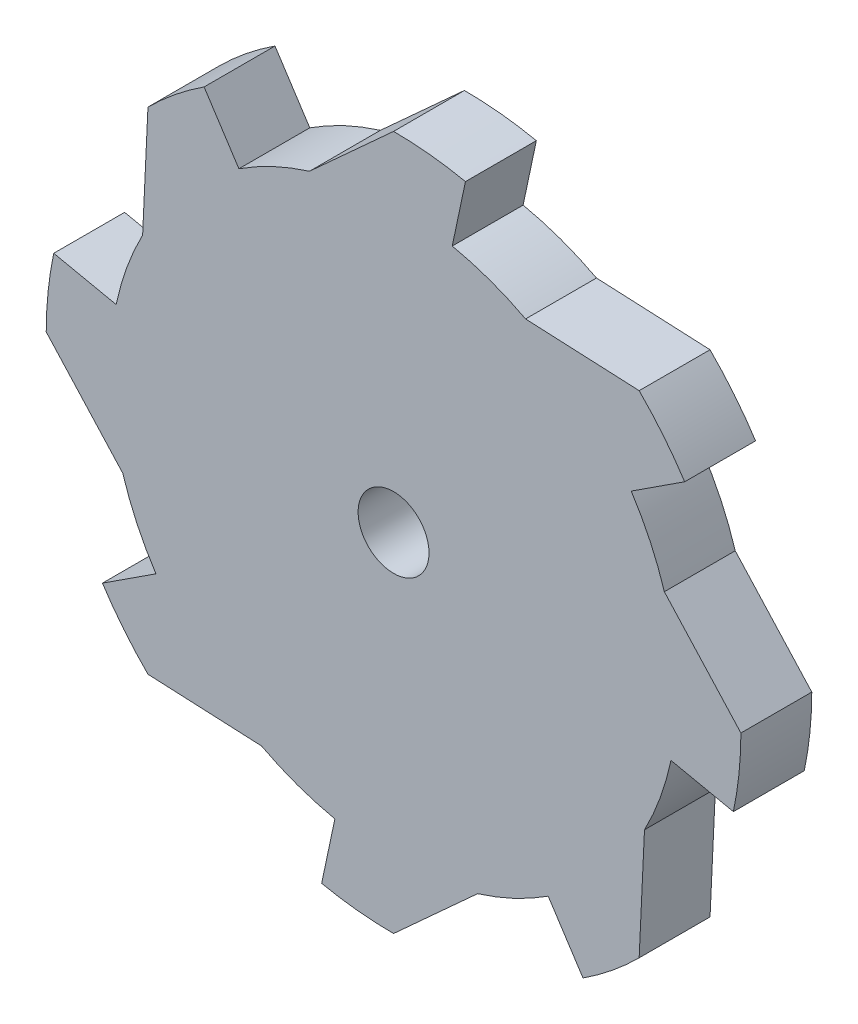
from build123d import *

# Parameters (mm, degrees)
BOSS_EXTRUDE1_DEPTH     = 20
CIRPATTERN1_COUNT       = 8
SKETCH3_R               = 10
CUT_EXTRUDE1_DEPTH      = 20
CUT_EXTRUDE1_DEPTH_BACK = 7


with BuildPart() as part:
    # Sketch1 → Boss-Extrude1 (new body)
    with BuildSketch(Plane.XY):
        with BuildLine():
            Line((95.877968476, -20.283371538), (78.267729368, -16.557854317))
            ThreePointArc((78.267729368, -16.557854317), (75.247619253, -27.162396743), (70.798070264, -37.250949611))
            Line((70.798070264, -37.250949611), (0, 0))
            Line((0, 0), (76.402194654, 23.721396503))
            Line((76.402194654, 23.721396503), (98, 0))
            ThreePointArc((98, 0), (97.468048382, -10.197036074), (95.877968476, -20.283371538))
        make_face()
    boss_extrude1 = extrude(amount=BOSS_EXTRUDE1_DEPTH)

    # CirPattern1: Boss-Extrude1 ×8 about axis
    cirpattern1_axis = Axis((0, 0, 0), (0, 0, 1))
    for i in range(1, CIRPATTERN1_COUNT):
        add(boss_extrude1.rotate(cirpattern1_axis, i * 360 / CIRPATTERN1_COUNT))

    # Sketch3 → Cut-Extrude1 (cut, two sides)
    with BuildSketch(Plane.XY) as cut_extrude1_sk:
        Circle(SKETCH3_R)
    extrude(amount=CUT_EXTRUDE1_DEPTH, mode=Mode.SUBTRACT)
    extrude(cut_extrude1_sk.sketch, amount=-CUT_EXTRUDE1_DEPTH_BACK, mode=Mode.SUBTRACT)


solid = part.part
